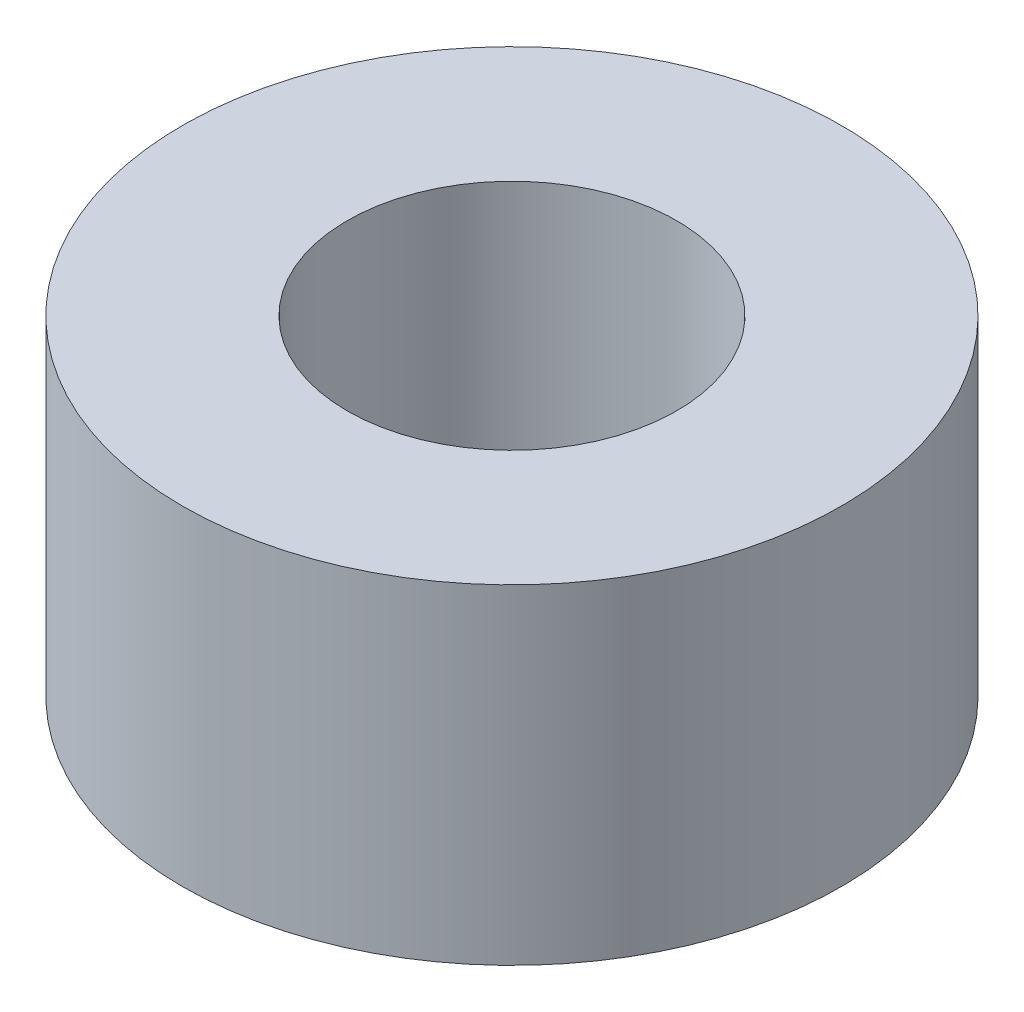
from build123d import *

# Parameters (mm, degrees)
SKETCH2_R               = 6.35
BOSS_EXTRUDE1_DEPTH     = 6.35
F_1_4_20_TAPPED_HOLE1_D = 6.35


with BuildPart() as part:
    # Sketch2 → Boss-Extrude1 (new body)
    with BuildSketch(Plane(origin=(0, 0, 0), x_dir=(1, 0, 0), z_dir=(0, 1, 0))):
        Circle(SKETCH2_R)
    extrude(amount=BOSS_EXTRUDE1_DEPTH)

    # 1/4-20 Tapped Hole1 (through all)
    with Locations(Plane(origin=(0, 6.35, 0), x_dir=(1, 0, 0), z_dir=(0, 1, 0))):
        with Locations((0, 0)):
            Hole(F_1_4_20_TAPPED_HOLE1_D / 2)


solid = part.part
